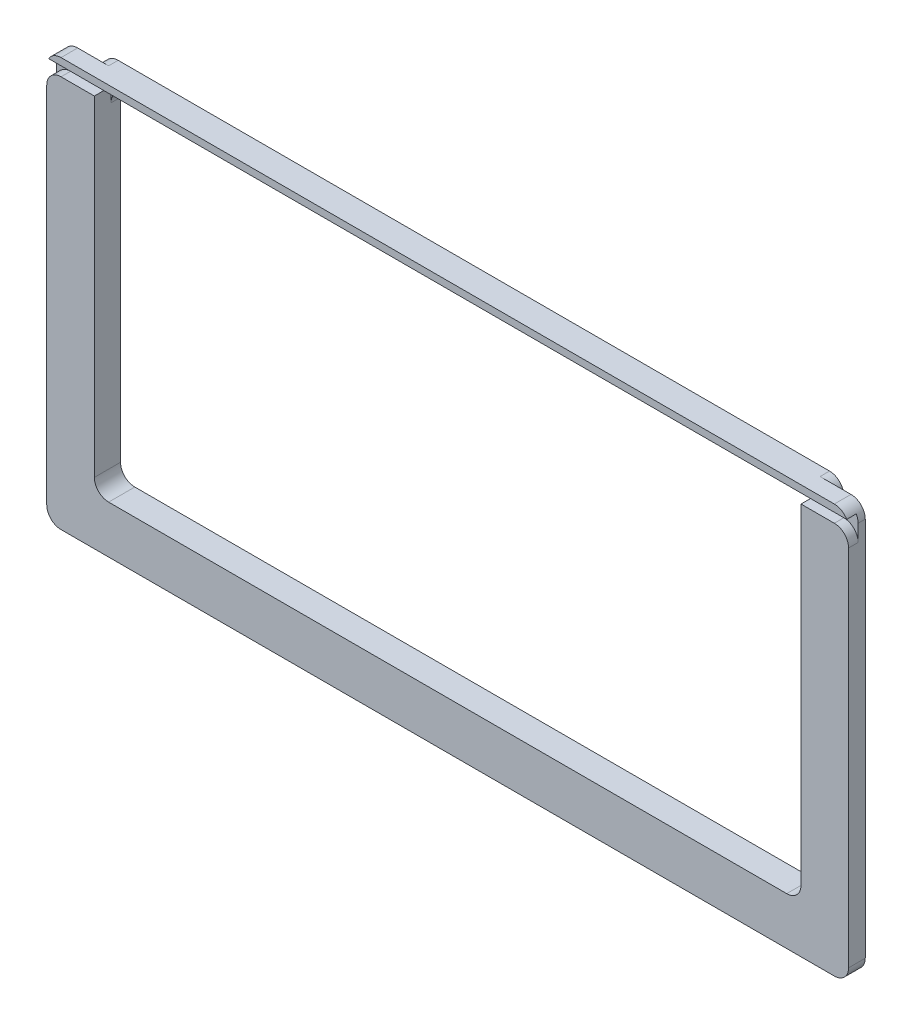
from build123d import *

# Parameters (mm, degrees)
SKETCH1_W           = 168.49
SKETCH1_H           = 85.9
BOSS_EXTRUDE1_DEPTH = 3.5
SKETCH2_W           = 148.49
SKETCH2_H           = 75.9
CUT_EXTRUDE1_DEPTH  = 3.5
SKETCH4_W           = 3.5
SKETCH4_H           = 1.5
BOSS_EXTRUDE2_DEPTH = 148.49
SKETCH5_W           = 2
SKETCH5_H           = 2
CUT_EXTRUDE2_DEPTH  = 176.5
FILLET3_R           = 3
FILLET4_R           = 3
SKETCH6_W           = 155.49
SKETCH6_H           = 79.4
SKETCH6_W_2         = 148.49
SKETCH6_H_2         = 72.4
BOSS_EXTRUDE3_DEPTH = 2
FILLET5_R           = 3
FILLET6_R           = 3
FILLET7_R           = 3
FILLET8_R           = 3


with BuildPart() as part:
    # Sketch1 → Boss-Extrude1 (new body)
    with BuildSketch(Plane.XY):
        Rectangle(SKETCH1_W, SKETCH1_H)
    extrude(amount=BOSS_EXTRUDE1_DEPTH)

    # Sketch2 → Cut-Extrude1 (cut)
    with BuildSketch(Plane.XY.offset(3.5)):
        with Locations((0, 5)):
            Rectangle(SKETCH2_W, SKETCH2_H)
    extrude(amount=-CUT_EXTRUDE1_DEPTH, mode=Mode.SUBTRACT)

    # Sketch4 → Boss-Extrude2 (add)
    with BuildSketch(Plane.ZY.offset(-74.245)):
        with Locations((1.75, 42.2)):
            Rectangle(SKETCH4_W, SKETCH4_H)
    extrude(amount=BOSS_EXTRUDE2_DEPTH)

    # Sketch5 → Cut-Extrude2 (cut)
    with BuildSketch(Plane(origin=(84.245, 0, 0), x_dir=(0, 0, -1), z_dir=(1, 0, 0))):
        with Locations((-2.5, 40.45)):
            Rectangle(SKETCH5_W, SKETCH5_H)
    extrude(amount=-CUT_EXTRUDE2_DEPTH, mode=Mode.SUBTRACT)

    # Fillet3
    fillet3_edges = [part.edges().sort_by_distance(p)[0] for p in [
        (-84.245, -42.95, 1.75),
    ]]
    fillet(fillet3_edges, radius=FILLET3_R)

    # Fillet4
    fillet4_edges = [part.edges().sort_by_distance(p)[0] for p in [
        (-84.245, 39.45, 2.5),
        (84.245, -42.95, 1.75),
    ]]
    fillet(fillet4_edges, radius=FILLET4_R)

    # Sketch6 → Boss-Extrude3 (add)
    with BuildSketch(Plane(origin=(0, 0, 0), x_dir=(-1, 0, 0), z_dir=(0, 0, -1))):
        with Locations((0, 3.25)):
            Rectangle(SKETCH6_W, SKETCH6_H)
        with Locations((0, 3.25)):
            Rectangle(SKETCH6_W_2, SKETCH6_H_2, mode=Mode.SUBTRACT)
    extrude(amount=BOSS_EXTRUDE3_DEPTH)

    # Fillet5
    fillet5_edges = [part.edges().sort_by_distance(p)[0] for p in [
        (84.245, 39.45, 2.5),
    ]]
    fillet(fillet5_edges, radius=FILLET5_R)

    # Fillet6
    fillet6_edges = [part.edges().sort_by_distance(p)[0] for p in [
        (-84.245, 42.95, 1.75),
        (84.245, 42.95, 1.75),
    ]]
    fillet(fillet6_edges, radius=FILLET6_R)

    # Fillet7
    fillet7_edges = [part.edges().sort_by_distance(p)[0] for p in [
        (77.745, 42.95, -1),
        (77.745, -36.45, -1),
        (-77.745, -36.45, -1),
        (-77.745, 42.95, -1),
    ]]
    fillet(fillet7_edges, radius=FILLET7_R)

    # Fillet8
    fillet8_edges = [part.edges().sort_by_distance(p)[0] for p in [
        (74.245, 39.45, -1),
        (-74.245, 39.45, -1),
        (-74.245, -32.95, 0.75),
        (74.245, -32.95, 0.75),
    ]]
    fillet(fillet8_edges, radius=FILLET8_R)


solid = part.part
